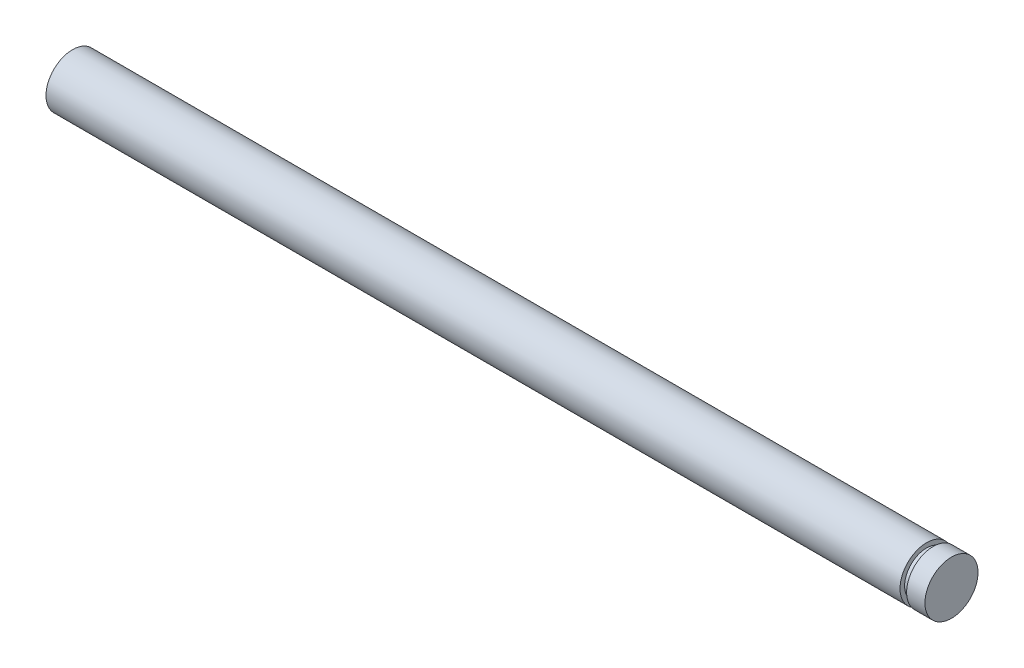
from build123d import *


with BuildPart() as part:
    # Sketch1 → Revolve1 (revolve)
    with BuildSketch(Plane.XY):
        Polygon((0, 0), (0, 0.725), (23.32, 0.725), (23.32, 0.6), (23.5, 0.6), (23.5, 0.725), (24, 0.725), (24, 0), align=None)
    revolve(axis=Axis((24, 0, 0), (-1, 0, 0)))


solid = part.part
